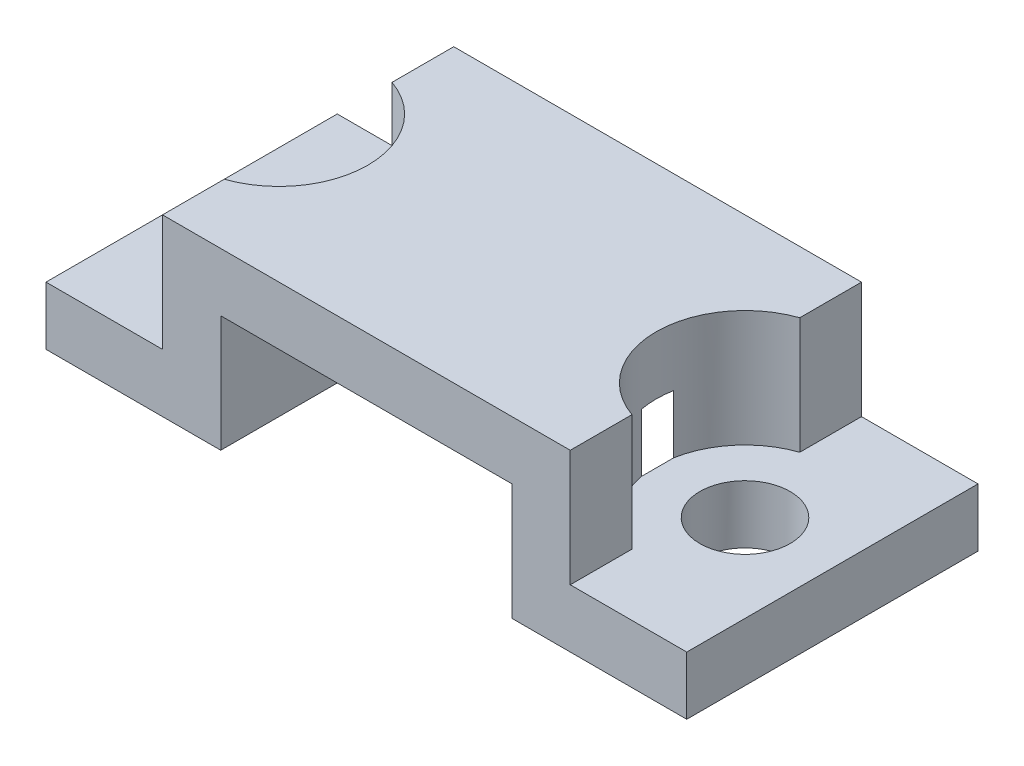
from build123d import *

# Parameters (mm, degrees)
SKETCH_1_W          = 22
SKETCH_1_H          = 10
EXTRUDE_1_DEPTH     = 6
SKETCH_2_W          = 10
SKETCH_2_H          = 4
SKETCH_2_W_2        = 4
CUT_EXTRUDE_1_DEPTH = 24
SKETCH_3_R          = 1.55
CUT_EXTRUDE_2_DEPTH = 6
SKETCH_3_3_R        = 3.05
CUT_EXTRUDE_3_DEPTH = 6


with BuildPart() as part:
    # 草图1 → 凸台-拉伸1 (new body)
    with BuildSketch(Plane(origin=(0, 0, 0), x_dir=(1, 0, 0), z_dir=(0, 1, 0))):
        Rectangle(SKETCH_1_W, SKETCH_1_H)
    extrude(amount=EXTRUDE_1_DEPTH)

    # 草图2 → 切除-拉伸1 (cut)
    with BuildSketch(Plane.XY.offset(5)):
        with Locations((0, 2)):
            Rectangle(SKETCH_2_W, SKETCH_2_H)
        with Locations((-9, 4)):
            Rectangle(SKETCH_2_W_2, SKETCH_2_H)
        with Locations((9, 4)):
            Rectangle(SKETCH_2_W_2, SKETCH_2_H)
    extrude(amount=-CUT_EXTRUDE_1_DEPTH, mode=Mode.SUBTRACT)

    # 草图3 → 切除-拉伸2 (cut)
    with BuildSketch(Plane(origin=(0, 2, 0), x_dir=(1, 0, 0), z_dir=(0, 1, 0))):
        with Locations((-8, 0)):
            Circle(SKETCH_3_R)
        with Locations((8, 0)):
            Circle(SKETCH_3_R)
    extrude(amount=-CUT_EXTRUDE_2_DEPTH, mode=Mode.SUBTRACT)

    # 草图3<3> → 切除-拉伸3 (cut)
    with BuildSketch(Plane(origin=(0, 2, 0), x_dir=(1, 0, 0), z_dir=(0, 1, 0))):
        with Locations((-8, 0)):
            Circle(SKETCH_3_3_R)
        with Locations((8, 0)):
            Circle(SKETCH_3_3_R)
    extrude(amount=CUT_EXTRUDE_3_DEPTH, mode=Mode.SUBTRACT)


solid = part.part
